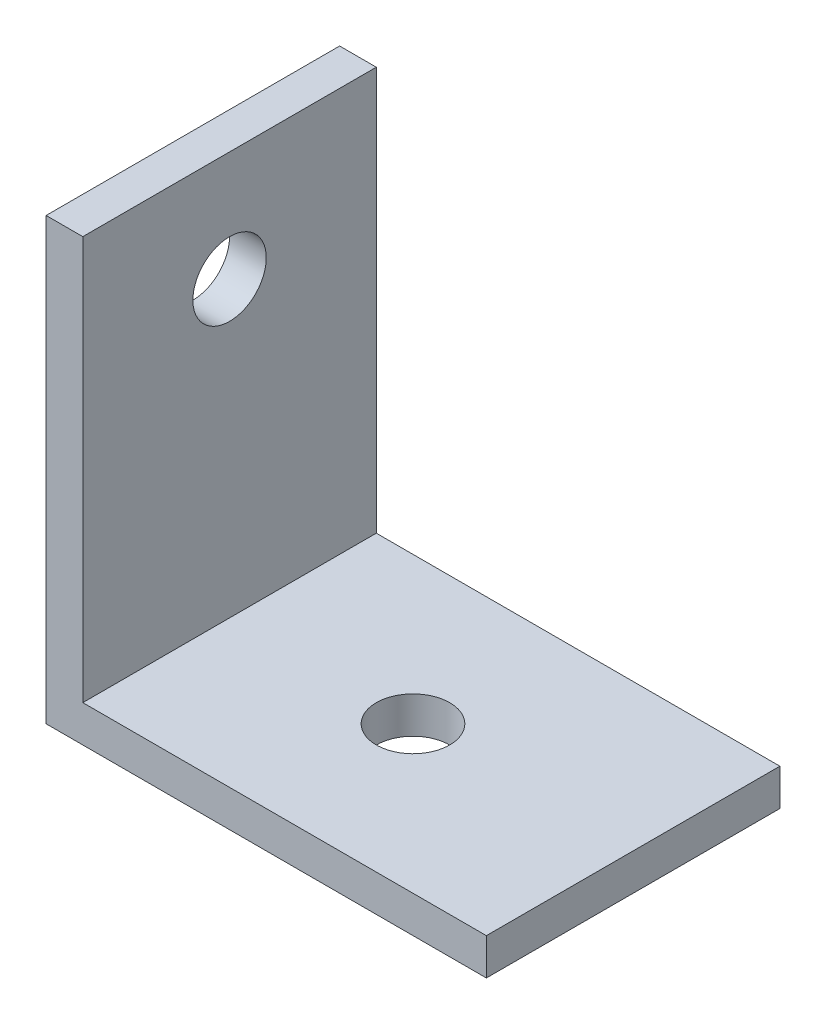
from build123d import *

# Parameters (mm, degrees)
BOSS_EXTRUDE1_DEPTH = 25.4
SKETCH2_R           = 3.175
CUT_EXTRUDE1_DEPTH  = 4.175
SKETCH3_R           = 3.175
CUT_EXTRUDE2_DEPTH  = 4.175


with BuildPart() as part:
    # Sketch1 → Boss-Extrude1 (new body)
    with BuildSketch(Plane.XY):
        Polygon((0, 0), (0, 38.1), (3.175, 38.1), (3.175, 3.175), (38.1, 3.175), (38.1, 0), align=None)
    extrude(amount=BOSS_EXTRUDE1_DEPTH)

    # Sketch2 → Cut-Extrude1 (cut, through all)
    with BuildSketch(Plane(origin=(0, 3.175, 0), x_dir=(1, 0, 0), z_dir=(0, 1, 0))):
        with Locations((19.05, -12.7)):
            Circle(SKETCH2_R)
    extrude(amount=-CUT_EXTRUDE1_DEPTH, mode=Mode.SUBTRACT)

    # Sketch3 → Cut-Extrude2 (cut, through all)
    with BuildSketch(Plane(origin=(3.175, 0, 0), x_dir=(0, 0, -1), z_dir=(1, 0, 0))):
        with Locations((-12.7, 28.575)):
            Circle(SKETCH3_R)
    extrude(amount=-CUT_EXTRUDE2_DEPTH, mode=Mode.SUBTRACT)


solid = part.part
